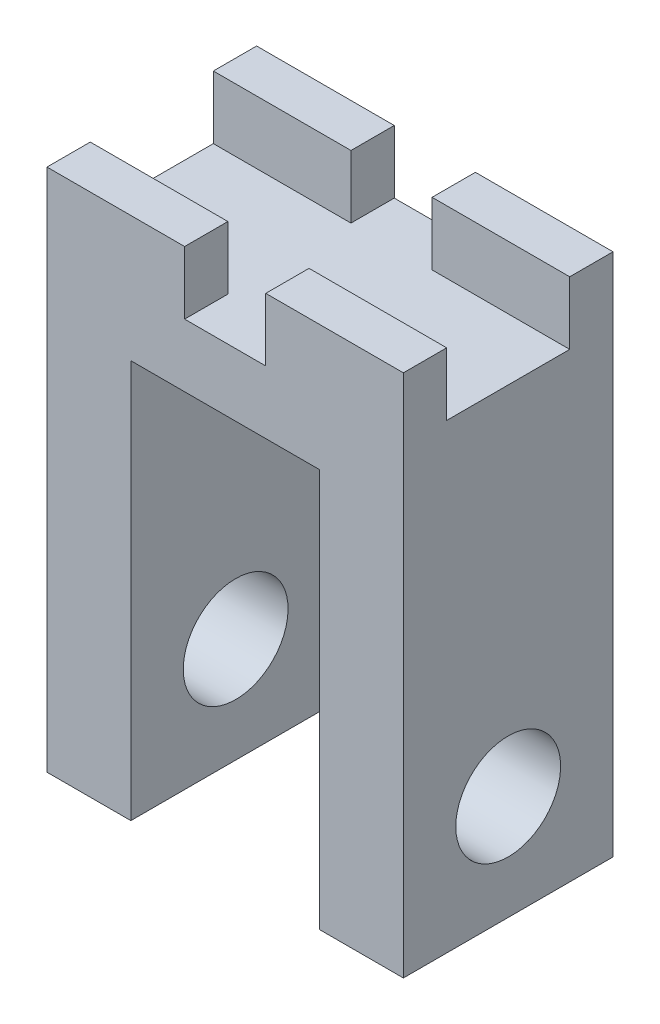
from build123d import *

# Parameters (mm, degrees)
BOSS_EXTRUDE1_DEPTH     = 10
CUT_EXTRUDE1_DEPTH      = 24.350588858
CUT_EXTRUDE1_DEPTH_BACK = 24.350588858
SKETCH2_R               = 2.5
SKETCH4_W               = 6.565
SKETCH4_H               = 2.065
BOSS_EXTRUDE2_DEPTH     = 3


with BuildPart() as part:
    # Sketch1 → Boss-Extrude1 (new body)
    with BuildSketch(Plane.XY):
        Polygon((-4.5, -9.5), (-4.5, 9.5), (4.5, 9.5), (4.5, -9.5), (8.5, -9.5), (8.5, 12.5), (-8.5, 12.5), (-8.5, -9.5), align=None)
    extrude(amount=BOSS_EXTRUDE1_DEPTH)

    # Sketch2 → Cut-Extrude1 (cut, two sides: drawn at the far end of the back side and taken through both)
    with BuildSketch(Plane.ZY.offset(8.5).offset(-CUT_EXTRUDE1_DEPTH_BACK)):
        with Locations((5, -4.5)):
            Circle(SKETCH2_R)
    extrude(amount=CUT_EXTRUDE1_DEPTH + CUT_EXTRUDE1_DEPTH_BACK, mode=Mode.SUBTRACT)

    # Sketch4 → Boss-Extrude2 (add)
    with BuildSketch(Plane(origin=(0, 12.5, 0), x_dir=(1, 0, 0), z_dir=(0, 1, 0))):
        with Locations((-5.2175, -1.0325)):
            Rectangle(SKETCH4_W, SKETCH4_H)
        with Locations((-5.2175, -8.9675)):
            Rectangle(SKETCH4_W, SKETCH4_H)
        with Locations((5.2175, -1.0325)):
            Rectangle(SKETCH4_W, SKETCH4_H)
        with Locations((5.2175, -8.9675)):
            Rectangle(SKETCH4_W, SKETCH4_H)
    extrude(amount=BOSS_EXTRUDE2_DEPTH)


solid = part.part
